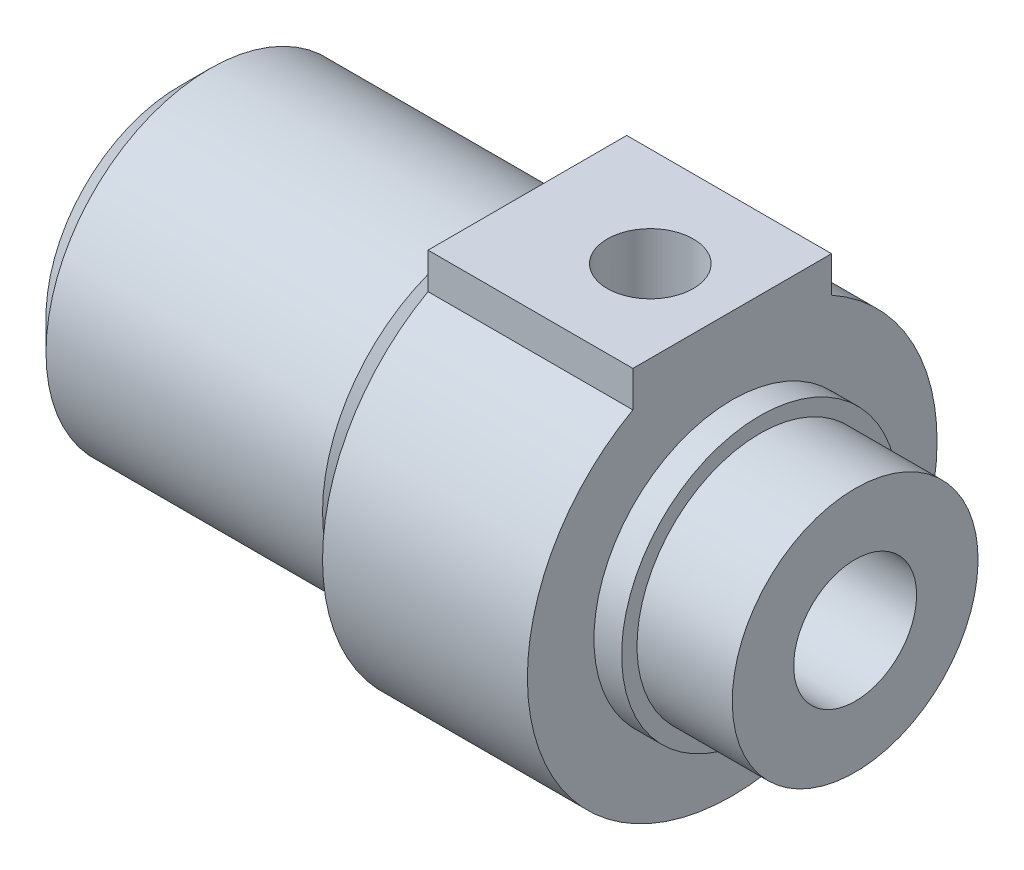
from build123d import *

# Parameters (mm, degrees)
BOSS_EXTRUDE1_DEPTH     = 33
CHAMFER1_SIZE           = 1.5
G1_8_TAPPED_HOLE1_D     = 4.2
G1_8_TAPPED_HOLE1_DEPTH = 11
G1_8_TAPPED_HOLE1_TIP   = 1.2618073
SKETCH6_R               = 3
CUT_EXTRUDE1_DEPTH      = 34


with BuildPart() as part:
    # Sketch1 → Boss-Extrude1 (new body)
    with BuildSketch(Plane(origin=(0, 0, 0), x_dir=(0, 0, -1), z_dir=(1, 0, 0))):
        with BuildLine():
            Line((-4.85, 8.745141508), (-4.85, 10.5))
            Line((-4.85, 10.5), (4.85, 10.5))
            Line((4.85, 10.5), (4.85, 8.745141508))
            ThreePointArc((4.85, 8.745141508), (0, -10), (-4.85, 8.745141508))
        make_face()
    extrude(amount=BOSS_EXTRUDE1_DEPTH)

    # Sketch2 → Cut-Revolve1 (revolve, cut)
    with BuildSketch(Plane.XY):
        Polygon((27, 14), (27, 6.75), (28.35, 6.75), (28.35, 6), (33, 6), (33, 14), align=None)
    revolve(axis=Axis((45.5, 0, 0), (-1, 0, 0)), mode=Mode.SUBTRACT)

    # Sketch3 → Cut-Revolve2 (revolve, cut)
    with BuildSketch(Plane.XY):
        Polygon((0, 8), (15, 8), (15.5, 7.5), (17, 7.5), (17, 16), (0, 16), align=None)
    revolve(axis=Axis((0, 0, 0), (1, 0, 0)), mode=Mode.SUBTRACT)

    # Chamfer1
    chamfer1_edges = [part.edges().sort_by_distance(p)[0] for p in [
        (0, -8, 0),
    ]]
    chamfer(chamfer1_edges, length=CHAMFER1_SIZE)

    # G1/8 Tapped Hole1
    with Locations(Plane(origin=(0, 10.5, 0), x_dir=(-1, 0, 0), z_dir=(0, 1, 0))):
        with Locations((-23, 0)):
            Hole(G1_8_TAPPED_HOLE1_D / 2, depth=G1_8_TAPPED_HOLE1_DEPTH)
            with Locations((0, 0, -(G1_8_TAPPED_HOLE1_DEPTH + G1_8_TAPPED_HOLE1_TIP / 2))):  # 118° drill point
                Cone(0, G1_8_TAPPED_HOLE1_D / 2, G1_8_TAPPED_HOLE1_TIP, mode=Mode.SUBTRACT)

    # Sketch6 → Cut-Extrude1 (cut, through all)
    with BuildSketch(Plane(origin=(33, 0, 0), x_dir=(0, 0, -1), z_dir=(1, 0, 0))):
        Circle(SKETCH6_R)
    extrude(amount=-CUT_EXTRUDE1_DEPTH, mode=Mode.SUBTRACT)


solid = part.part
